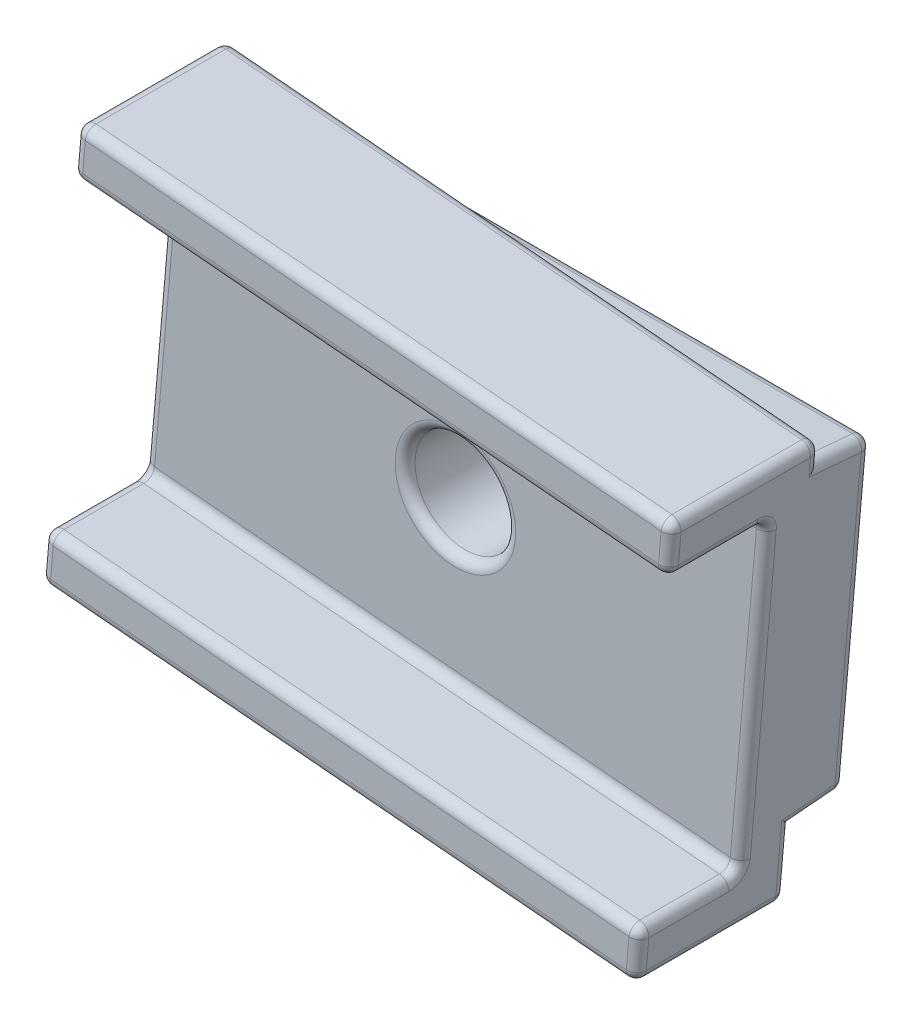
from build123d import *

# Parameters (mm, degrees)
SKETCH1_W           = 60.00000000000001
SKETCH1_H           = 32
BOSS_EXTRUDE1_DEPTH = 5.3
BOSS_EXTRUDE2_DEPTH = 60
SKETCH4_R           = 5.050000000000001
BOSS_EXTRUDE3_DEPTH = 5
BOSS_EXTRUDE4_DEPTH = 15
BOSS_EXTRUDE5_DEPTH = 5.3
CUT_EXTRUDE1_DEPTH  = 10
CUT_EXTRUDE2_DEPTH  = 5
CUT_EXTRUDE3_DEPTH  = 5
CUT_EXTRUDE4_START  = -15
SKETCH4_4_R         = 5.050000000000001
CUT_EXTRUDE4_DEPTH  = 15
FILLET1_R           = 1


with BuildPart() as part:
    # Sketch1 → Boss-Extrude1 (new body)
    with BuildSketch(Plane.XY):
        with Locations((30.000000000000004, 16)):
            Rectangle(SKETCH1_W, SKETCH1_H)
    extrude(amount=BOSS_EXTRUDE1_DEPTH)

    # Sketch3 → Boss-Extrude2 (add)
    with BuildSketch(Plane.ZY):
        Polygon((5.29999999999999, 32), (5.29999999999999, 32.5), (0, 32), align=None)
        Polygon((5.3, -0.5), (5.3, 0), (0, 0), align=None)
    extrude(amount=-BOSS_EXTRUDE2_DEPTH)

    # Sketch4 → Boss-Extrude3 (add)
    # profile 1 of 9: a face of its own
    with BuildSketch(Plane.XY.offset(5.3)):
        Polygon((1.3289678218773275, 32.5), (24.983548935155518, 32.5), (1.5086509412101563, 34.55378745189766), align=None)
    # profile 2 of 9: a face of its own
    with BuildSketch(Plane.XY.offset(5.3)):
        Polygon((0, 2.5635425050841554), (35.01645106484395, -0.4999999999999578), (58.671032178122694, -0.5000000000000004), (59.999999999999964, 14.690171712744215), (60, 29.43645749491585), (24.983548935155518, 32.5), (1.3289678218773275, 32.5), (-4e-15, 17.309828287255154), align=None)
        with Locations((30, 16)):
            Circle(SKETCH4_R, mode=Mode.SUBTRACT)
    # profile 3 of 9: a face of its own
    with BuildSketch(Plane.XY.offset(5.3)):
        Polygon((0, -0.5000000000000004), (35.01645106484395, -0.5000000000000004), (0, 2.5635425050841554), align=None)
    # profile 4 of 9: a face of its own
    with BuildSketch(Plane.XY.offset(5.3)):
        Polygon((58.055570345051585, -7.534760942356384), (58.49134905878986, -2.553787451897688), (35.01645106484395, -0.4999999999999578), (0, -0.5000000000000004), (0, 2.5635425050841576), (-1.2803328267148615, 2.675557112961807), (-1.7161115404531533, -2.3054163774969894), align=None)
    # profile 5 of 9: a face of its own
    with BuildSketch(Plane.XY.offset(5.3)):
        Polygon((35.01645106484395, -0.4999999999999578), (58.49134905878986, -2.5537874518976778), (58.671032178122694, -0.5000000000000071), align=None)
    # profile 6 of 9: a face of its own
    with BuildSketch(Plane.XY.offset(5.3)):
        Polygon((59.999999999999964, 14.690171712744215), (61.28033282671488, 29.324442887038195), (60, 29.436457494915846), align=None)
    # profile 7 of 9: a face of its own
    with BuildSketch(Plane.XY.offset(5.3)):
        Polygon((24.983548935155518, 32.5), (60, 29.436457494915846), (60, 32.5), align=None)
    # profile 8 of 9: a face of its own
    with BuildSketch(Plane.XY.offset(5.3)):
        Polygon((60, 29.436457494915846), (61.28033282671488, 29.324442887038195), (61.71611154045317, 34.305416377497), (1.944429654948438, 39.5347609423564), (1.5086509412101552, 34.55378745189767), (24.983548935155518, 32.5), (60, 32.5), align=None)
    # profile 9 of 9: a face of its own
    with BuildSketch(Plane.XY.offset(5.3)):
        Polygon((-1.2803328267148615, 2.675557112961807), (0, 2.5635425050841554), (0, 17.309828287255158), align=None)
    extrude(amount=BOSS_EXTRUDE3_DEPTH)

    # Sketch4_3 → Boss-Extrude4 (add)
    with BuildSketch(Plane.XY.offset(5.3)):
        Polygon((60, 29.436457494915846), (61.28033282671488, 29.324442887038195), (61.71611154045317, 34.305416377497), (1.944429654948438, 39.5347609423564), (1.5086509412101552, 34.55378745189767), (24.983548935155518, 32.5), (60, 32.5), align=None)
        Polygon((24.983548935155518, 32.5), (60, 29.436457494915846), (60, 32.5), align=None)
        Polygon((58.055570345051585, -7.534760942356384), (58.49134905878986, -2.553787451897688), (35.01645106484395, -0.4999999999999578), (0, -0.5000000000000004), (0, 2.5635425050841576), (-1.2803328267148615, 2.675557112961807), (-1.7161115404531533, -2.3054163774969894), align=None)
        Polygon((0, -0.5000000000000004), (35.01645106484395, -0.5000000000000004), (0, 2.5635425050841554), align=None)
    extrude(amount=BOSS_EXTRUDE4_DEPTH)

    # Sketch6 → Boss-Extrude5 (add)
    with BuildSketch(Plane(origin=(0, 0, 5.3), x_dir=(-1, 0, 0), z_dir=(0, 0, -1))):
        Polygon((-2.2e-16, 17.3098282872552), (0, -0.5000000000000004), (1.558158074478129, -0.499999999999997), align=None)
        Polygon((-60.00000000000001, 14.690171712744698), (-60, 32.5), (-61.55815807447815, 32.5), align=None)
    extrude(amount=BOSS_EXTRUDE5_DEPTH)

    # Sketch5 → Cut-Extrude1 (cut)
    with BuildSketch(Plane.XY.offset(5.3)):
        Polygon((58.671032178122694, -0.5000000000000004), (60, -0.5000000000000004), (60.00000000000001, 14.690171712744698), align=None)
        Polygon((1.328967821877318, 32.5), (0, 32.5), (2.2e-16, 17.3098282872552), align=None)
    extrude(amount=-CUT_EXTRUDE1_DEPTH, mode=Mode.SUBTRACT)

    # Sketch7 → Cut-Extrude2 (cut)
    with BuildSketch(Plane(origin=(0, 0, 0), x_dir=(0, 0, -1), z_dir=(1, -1e-17, 0))):
        Polygon((0, -0.5000000000000004), (3.2e-16, 3.5e-15), (-5.3, -0.5000000000000004), align=None)
    extrude(amount=-CUT_EXTRUDE2_DEPTH, mode=Mode.SUBTRACT)

    # Sketch8 → Cut-Extrude3 (cut)
    with BuildSketch(Plane.ZY.offset(-60.000000000000014)):
        Polygon((5.299999999999987, 32.49999999999998), (0, 31.99999999999998), (0, 32.49999999999998), align=None)
    extrude(amount=-CUT_EXTRUDE3_DEPTH, mode=Mode.SUBTRACT)

    # Sketch4_4 → Cut-Extrude4 (cut)
    with BuildSketch(Plane.XY.offset(5.3).offset(CUT_EXTRUDE4_START)):
        with Locations(Location((30, 16, 0), (0, 0, 180))):
            Circle(SKETCH4_4_R)
    extrude(amount=CUT_EXTRUDE4_DEPTH, mode=Mode.SUBTRACT)

    # Fillet1
    fillet1_edges = [part.edges().sort_by_distance(p)[0] for p in [
        (-1.637134807465641, -1.402708188748493, 5.3),
        (58.692904344004184, -0.25000000000000244, 2.65),
        (1.307095655995838, 32.25, 2.6499999999999977),
        (-0.11459512630040658, 16.000000000000004, 0),
        (-1.5362859085966487, -0.24999999999999853, 2.65),
        (60.11459512630042, 15.999999999999996, 0),
        (61.53628590859667, 32.25, 2.6499999999999937),
        (35.05, 16, 0),
        (58.36330126158714, -4.017380471178193, 5.3),
        (61.63713480746566, 33.4027081887485, 5.3),
        (31.830270597700803, 36.920088659926705, 5.3),
        (1.6366987384128773, 36.0173804711782, 5.299999999999997),
        (1.944429654948438, 39.5347609423564, 12.8),
        (28.169729402299218, -4.920088659926687, 5.3),
        (-1.7161115404531533, -2.3054163774969894, 12.8),
        (58.055570345051585, -7.534760942356385, 12.8),
        (61.71611154045317, 34.305416377497, 12.8),
        (24.95, 16, 10.3),
        (31.399818616414773, 32, 0),
        (28.60018138358524, 1.74e-15, -8e-17),
        (0.11415905724764364, 18.61467228242972, 10.3),
        (59.885840942752374, 13.38532771757026, 10.3),
        (31.394491883962516, 31.939115169467932, 10.3),
        (1.7265402980792965, 37.04427419712704, 20.3),
        (1.5086509412101559, 34.55378745189766, 15.3),
        (31.39449188396252, 31.93911516946793, 20.3),
        (61.28033282671488, 29.324442887038195, 15.3),
        (31.830270597700803, 36.920088659926705, 20.3),
        (61.498222183584026, 31.814929632267596, 20.3),
        (28.605508116037498, 0.06088483053206062, 10.3),
        (58.49134905878986, -2.5537874518976826, 15.3),
        (-1.2803328267148655, 2.675557112961773, 15.3),
        (58.27345970192072, -5.044274197127036, 20.3),
        (28.605508116037498, 0.06088483053204508, 20.3),
        (-1.4982221835840113, 0.18507036773237484, 20.3),
        (28.169729402299218, -4.920088659926687, 20.3),
    ]]
    fillet(fillet1_edges, radius=FILLET1_R)


solid = part.part
